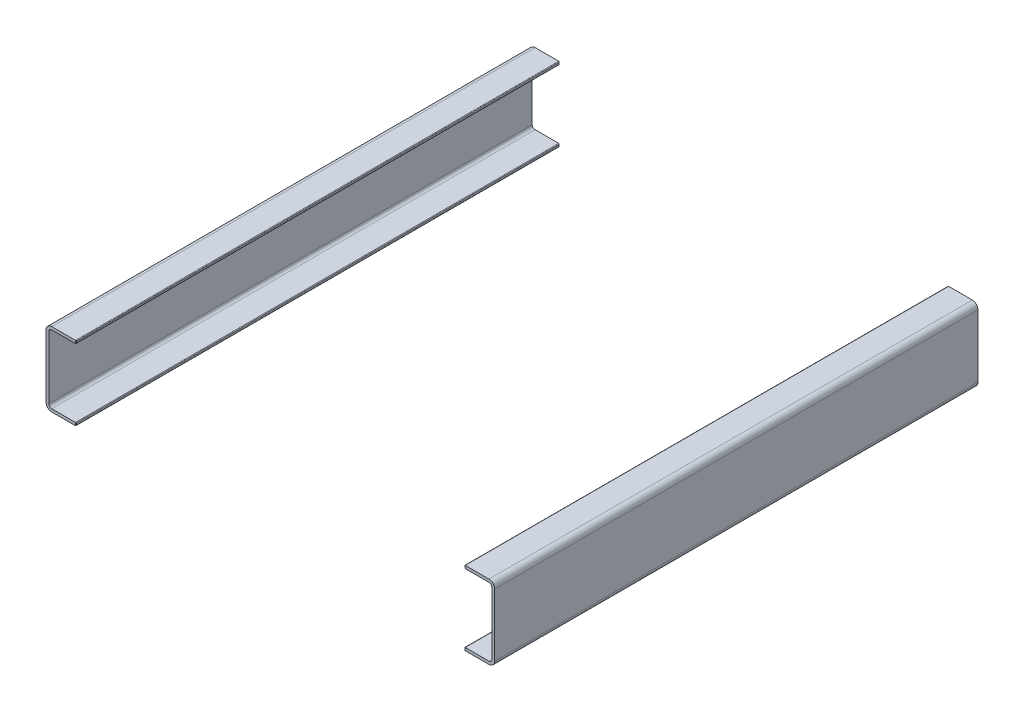
from build123d import *

# Parameters (mm, degrees)
SKETCH6_W           = 306
SKETCH6_H           = 46.8
BOSS_EXTRUDE2_DEPTH = 19
SKETCH7_W           = 17.2
SKETCH7_H           = 43.2
CUT_EXTRUDE2_DEPTH  = 307
FILLET4_R           = 0.4
FILLET5_R           = 1.8
FILLET6_R           = 3.6
SKETCH12_W          = 306
SKETCH12_H          = 46.8
BOSS_EXTRUDE3_DEPTH = 19
SKETCH13_W          = 17.2
SKETCH13_H          = 43.2
CUT_EXTRUDE3_DEPTH  = 307
FILLET7_R           = 0.4
FILLET8_R           = 1.8
FILLET9_R           = 3.6


with BuildPart() as part:
    # Sketch6 → Boss-Extrude2 (new body)
    with BuildSketch(Plane.ZY.offset(-123)):
        Rectangle(SKETCH6_W, SKETCH6_H)
    extrude(amount=-BOSS_EXTRUDE2_DEPTH)

    # Sketch7 → Cut-Extrude2 (cut, through all)
    with BuildSketch(Plane.XY.offset(153)):
        with Locations((131.6, 0)):
            Rectangle(SKETCH7_W, SKETCH7_H)
    extrude(amount=-CUT_EXTRUDE2_DEPTH, mode=Mode.SUBTRACT)

    # Fillet4
    fillet4_edges = [part.edges().sort_by_distance(p)[0] for p in [
        (123, 22.5, 153),
        (123, -22.5, -153),
        (123, -21.6, 0),
        (123, 21.6, 0),
        (123, -23.4, 0),
        (123, 22.5, -153),
        (123, 23.4, 0),
        (123, -22.5, 153),
    ]]
    fillet(fillet4_edges, radius=FILLET4_R)

    # Fillet5
    fillet5_edges = [part.edges().sort_by_distance(p)[0] for p in [
        (140.2, 21.6, 0),
        (140.2, -21.6, 0),
    ]]
    fillet(fillet5_edges, radius=FILLET5_R)

    # Fillet6
    fillet6_edges = [part.edges().sort_by_distance(p)[0] for p in [
        (142, -23.4, 0),
        (142, 23.4, 0),
    ]]
    fillet(fillet6_edges, radius=FILLET6_R)


with BuildPart() as body_2:
    # Sketch12 → Boss-Extrude3 (new body)
    with BuildSketch(Plane(origin=(-123, 0, 0), x_dir=(0, 0, -1), z_dir=(1, 0, 0))):
        Rectangle(SKETCH12_W, SKETCH12_H)
    extrude(amount=-BOSS_EXTRUDE3_DEPTH)

    # Sketch13 → Cut-Extrude3 (cut, through all)
    with BuildSketch(Plane.XY.offset(153)):
        with Locations((-131.6, 0)):
            Rectangle(SKETCH13_W, SKETCH13_H)
    extrude(amount=-CUT_EXTRUDE3_DEPTH, mode=Mode.SUBTRACT)

    # Fillet7
    fillet7_edges = [body_2.edges().sort_by_distance(p)[0] for p in [
        (-123, -22.5, 153),
        (-123, 22.5, -153),
        (-123, -21.6, 0),
        (-123, 21.6, 0),
        (-123, -22.5, -153),
        (-123, -23.4, 0),
        (-123, 22.5, 153),
        (-123, 23.4, 0),
    ]]
    fillet(fillet7_edges, radius=FILLET7_R)

    # Fillet8
    fillet8_edges = [body_2.edges().sort_by_distance(p)[0] for p in [
        (-140.2, -21.6, 0),
        (-140.2, 21.6, 0),
    ]]
    fillet(fillet8_edges, radius=FILLET8_R)

    # Fillet9
    fillet9_edges = [body_2.edges().sort_by_distance(p)[0] for p in [
        (-142, -23.4, 0),
        (-142, 23.4, 0),
    ]]
    fillet(fillet9_edges, radius=FILLET9_R)


solid = Compound([part.part, body_2.part])
